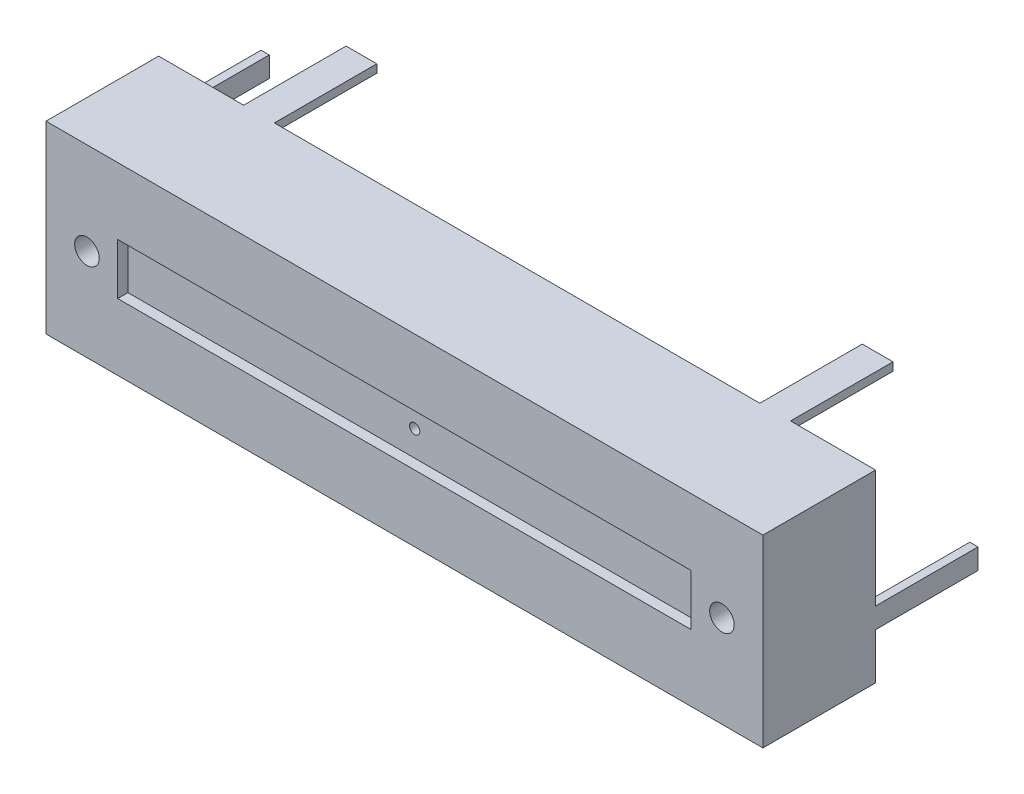
from build123d import *

# Parameters (mm, degrees)
BODY_2_W                        = 35
BODY_2_H                        = 9
BODY_DEPTH                      = 5.5
HOLES_2_R                       = 0.6
HOLES_DEPTH                     = 1
CHANNEL_2_W                     = 28
CHANNEL_2_H                     = 2.5
CHANNEL_DEPTH                   = 0.5
CONNECTION_PINS_2_W             = 1.5
CONNECTION_PINS_2_H             = 0.4
CONNECTION_PINS_2_W_2           = 0.4
CONNECTION_PINS_2_H_2           = 1
CONNECTION_PINS_DEPTH           = 5
SKIZZE1_R                       = 0.25
SCHNITT_LINEAR_AUSTRAGEN1_DEPTH = 11


with BuildPart() as part:
    # body 2 → body (new body)
    with BuildSketch(Plane.XY):
        Rectangle(BODY_2_W, BODY_2_H)
    extrude(amount=BODY_DEPTH)

    # holes 2 → holes (cut)
    with BuildSketch(Plane.XY.offset(5.5)):
        with Locations((-15.5, 0)):
            Circle(HOLES_2_R)
        with Locations((15.5, 0)):
            Circle(HOLES_2_R)
    extrude(amount=-HOLES_DEPTH, mode=Mode.SUBTRACT)

    # channel 2 → channel (cut)
    with BuildSketch(Plane.XY.offset(5.5)):
        Rectangle(CHANNEL_2_W, CHANNEL_2_H)
    extrude(amount=-CHANNEL_DEPTH, mode=Mode.SUBTRACT)

    # connection pins 2 → connection pins (add)
    with BuildSketch(Plane(origin=(0, 0, 0), x_dir=(-1, 0, 0), z_dir=(0, 0, -1))):
        with Locations((-12.6, 4.3)):
            Rectangle(CONNECTION_PINS_2_W, CONNECTION_PINS_2_H)
        with Locations((12.6, 4.3)):
            Rectangle(CONNECTION_PINS_2_W, CONNECTION_PINS_2_H)
        with Locations((-11.4, -4.3)):
            Rectangle(CONNECTION_PINS_2_W, CONNECTION_PINS_2_H)
        with Locations((-17.3, -1.75)):
            Rectangle(CONNECTION_PINS_2_W_2, CONNECTION_PINS_2_H_2)
        with Locations((11.4, -4.3)):
            Rectangle(CONNECTION_PINS_2_W, CONNECTION_PINS_2_H)
        with Locations((17.3, 1.75)):
            Rectangle(CONNECTION_PINS_2_W_2, CONNECTION_PINS_2_H_2)
        with Locations((17.3, -1.75)):
            Rectangle(CONNECTION_PINS_2_W_2, CONNECTION_PINS_2_H_2)
    extrude(amount=CONNECTION_PINS_DEPTH)

    # Skizze1 → Schnitt-Linear austragen1 (cut, through all)
    with BuildSketch(Plane.XY.offset(5)):
        Circle(SKIZZE1_R)
    extrude(amount=-SCHNITT_LINEAR_AUSTRAGEN1_DEPTH, mode=Mode.SUBTRACT)


solid = part.part
